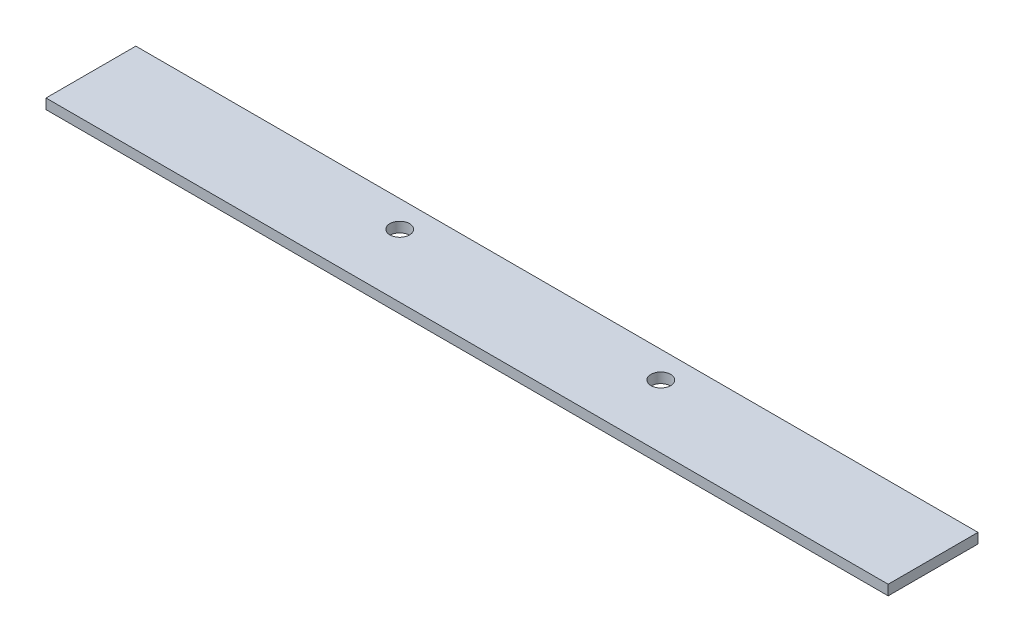
from build123d import *

# Parameters (mm, degrees)
CROQUIS1_W              = 150
CROQUIS1_H              = 16
SALIENTE_EXTRUIR1_DEPTH = 1.8
CROQUIS2_R              = 1.75
CORTAR_EXTRUIR1_DEPTH   = 2.8


with BuildPart() as part:
    # Croquis1 → Saliente-Extruir1 (new body)
    with BuildSketch(Plane(origin=(0, 0, 0), x_dir=(1, 0, 0), z_dir=(0, 1, 0))):
        Rectangle(CROQUIS1_W, CROQUIS1_H)
    extrude(amount=SALIENTE_EXTRUIR1_DEPTH)

    # Croquis2 → Cortar-Extruir1 (cut, through all)
    with BuildSketch(Plane(origin=(0, 1.8, 0), x_dir=(1, 0, 0), z_dir=(0, 1, 0))):
        with Locations((-23.25, 3.25)):
            Circle(CROQUIS2_R)
        with Locations((23.25, 3.25)):
            Circle(CROQUIS2_R)
    extrude(amount=-CORTAR_EXTRUIR1_DEPTH, mode=Mode.SUBTRACT)


solid = part.part
